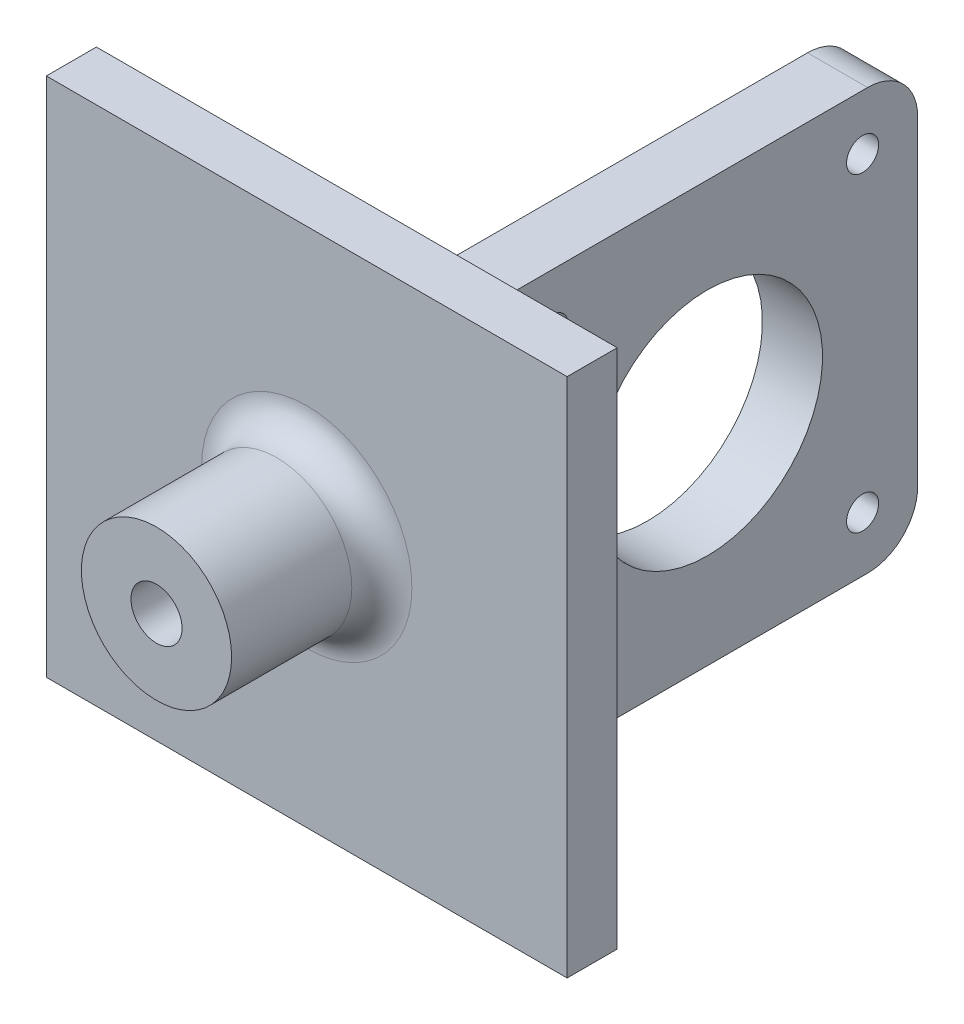
from build123d import *

# Parameters (mm, degrees)
SKETCH_1_R          = 26
EXTRUDE_1_DEPTH     = 5
SKETCH_2_R          = 7.5
SKETCH_2_R_2        = 2.55
EXTRUDE_2_DEPTH     = 15
SKETCH_4_R          = 1.6
CUT_EXTRUDE_1_DEPTH = 20
SKETCH_6_R          = 40.158600147
EXTRUDE_4_DEPTH     = 5
SKETCH_7_R          = 40.158600147
SKETCH_7_W          = 52
SKETCH_7_H          = 52
CUT_EXTRUDE_2_DEPTH = 5
SKETCH_8_W          = 6
SKETCH_8_H          = 42
EXTRUDE_5_DEPTH     = 45
SKETCH_9_R          = 11.5
SKETCH_9_R_2        = 1.6
CUT_EXTRUDE_3_DEPTH = 10
FILLET_1_R          = 5
FILLET_2_R          = 3


with BuildPart() as part:
    # 草图1 → 凸台-拉伸1 (new body)
    with BuildSketch(Plane.XY):
        with Locations((-2.038900501, 7.884914675)):
            Circle(SKETCH_1_R)
    extrude(amount=EXTRUDE_1_DEPTH)

    # 草图2 → 凸台-拉伸2 (add)
    with BuildSketch(Plane.XY.offset(5)):
        with Locations((-2.038900501, 7.884914675)):
            Circle(SKETCH_2_R)
        with Locations((-2.038900501, 7.884914675)):
            Circle(SKETCH_2_R_2, mode=Mode.SUBTRACT)
    extrude(amount=EXTRUDE_2_DEPTH)

    # 草图4 → 切除-拉伸1 (cut)
    with BuildSketch(Plane.ZY.offset(28.038900501)):
        with Locations((12.5, 7.884914675)):
            Circle(SKETCH_4_R)
    extrude(amount=-CUT_EXTRUDE_1_DEPTH, mode=Mode.SUBTRACT)

    # 草图6 → 凸台-拉伸4 (add)
    with BuildSketch(Plane(origin=(0, 0, 0), x_dir=(-1, 0, 0), z_dir=(0, 0, -1))):
        with Locations((2.038900501, 7.884914675)):
            Circle(SKETCH_6_R)
    extrude(amount=-EXTRUDE_4_DEPTH)

    # 草图7 → 切除-拉伸2 (cut)
    with BuildSketch(Plane(origin=(0, 0, 0), x_dir=(-1, 0, 0), z_dir=(0, 0, -1))):
        with Locations((2.038900501, 7.884914675)):
            Circle(SKETCH_7_R)
        with Locations((2.038900501, 7.884914675)):
            Rectangle(SKETCH_7_W, SKETCH_7_H, mode=Mode.SUBTRACT)
    extrude(amount=-CUT_EXTRUDE_2_DEPTH, mode=Mode.SUBTRACT)

    # 草图8 → 凸台-拉伸5 (add)
    with BuildSketch(Plane(origin=(0, 0, 0), x_dir=(-1, 0, 0), z_dir=(0, 0, -1))):
        with Locations((-5.961099499, 7.884914675)):
            Rectangle(SKETCH_8_W, SKETCH_8_H)
    extrude(amount=EXTRUDE_5_DEPTH)

    # 草图9 → 切除-拉伸3 (cut)
    with BuildSketch(Plane(origin=(8.961099499, 0, 0), x_dir=(0, 0, -1), z_dir=(1, 0, 0))):
        with Locations((24, 7.884914675)):
            Circle(SKETCH_9_R)
        with Locations((39.5, 23.384914675)):
            Circle(SKETCH_9_R_2)
        with Locations((8.5, -7.615085325)):
            Circle(SKETCH_9_R_2)
        with Locations((39.5, -7.615085325)):
            Circle(SKETCH_9_R_2)
        with Locations((8.5, 23.384914675)):
            Circle(SKETCH_9_R_2)
    extrude(amount=-CUT_EXTRUDE_3_DEPTH, mode=Mode.SUBTRACT)

    # 圆角1
    fillet_1_edges = [part.edges().sort_by_distance(p)[0] for p in [
        (5.961099499, -13.115085325, -45),
        (5.961099499, 28.884914675, -45),
    ]]
    fillet(fillet_1_edges, radius=FILLET_1_R)

    # 圆角2
    fillet_2_edges = [part.edges().sort_by_distance(p)[0] for p in [
        (8.961099499, 7.884914675, 0),
        (5.961099499, -13.115085325, 0),
        (2.961099499, 7.884914675, 0),
        (5.961099499, 28.884914675, 0),
        (-9.538900501, 7.884914675, 5),
    ]]
    fillet(fillet_2_edges, radius=FILLET_2_R)


solid = part.part
